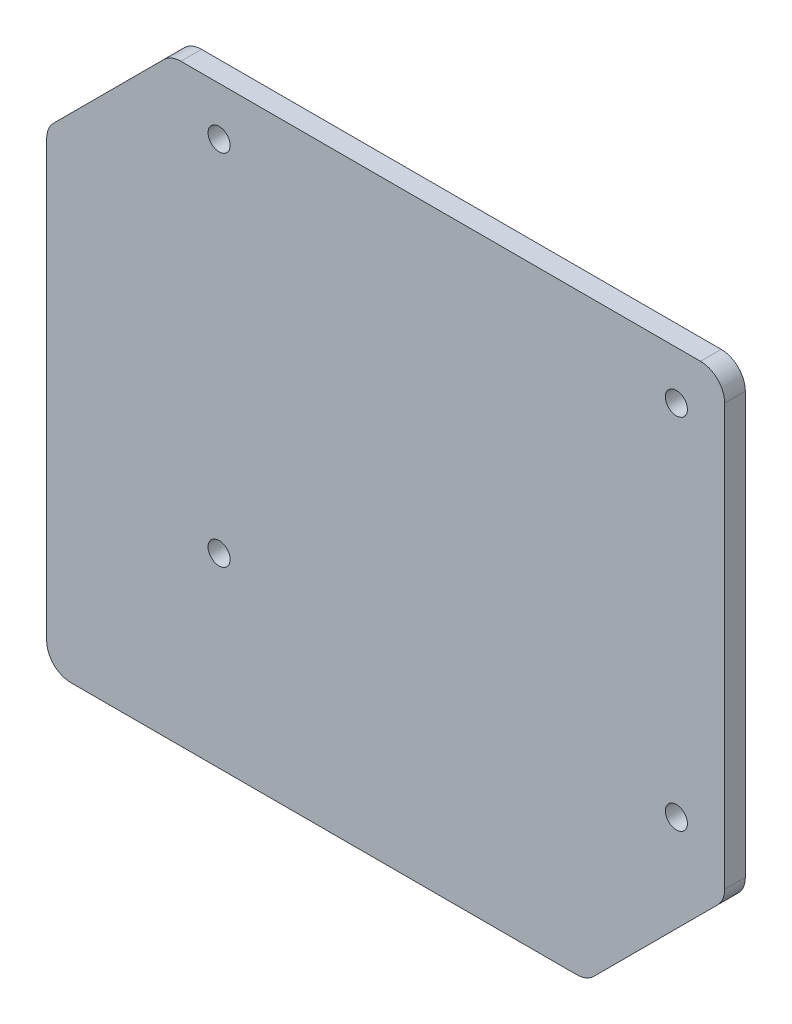
from build123d import *

# Parameters (mm, degrees)
SKETCH1_W                  = 80.3
SKETCH1_H                  = 66
BOSS_EXTRUDE1_DEPTH        = 3
FILLET1_R                  = 3.5
F_3_2_3_2_DIAMETER_HOLE1_D = 3.2


with BuildPart() as part:
    # Sketch1 → Boss-Extrude1 (new body)
    with BuildSketch(Plane.XY):
        Polygon((-18, -20), (60.3, -20), (80.3, 0), (0, 0), (0, 66), (-18, 48), align=None)
        with Locations((40.15, 33)):
            Rectangle(SKETCH1_W, SKETCH1_H)
    extrude(amount=BOSS_EXTRUDE1_DEPTH)

    # Fillet1
    fillet1_edges = [part.edges().sort_by_distance(p)[0] for p in [
        (60.3, -20, 1.5),
        (-18, -20, 1.5),
        (-18, 48, 1.5),
        (0, 66, 1.5),
        (80.3, 66, 1.5),
        (80.3, 0, 1.5),
    ]]
    fillet(fillet1_edges, radius=FILLET1_R)

    # Ø3.2 (3.2) Diameter Hole1 (through all)
    with Locations(Plane.XY.offset(3)):
        with Locations((7, 59), (73.3, 59), (73.3, 7), (7, 7)):
            Hole(F_3_2_3_2_DIAMETER_HOLE1_D / 2)


solid = part.part
